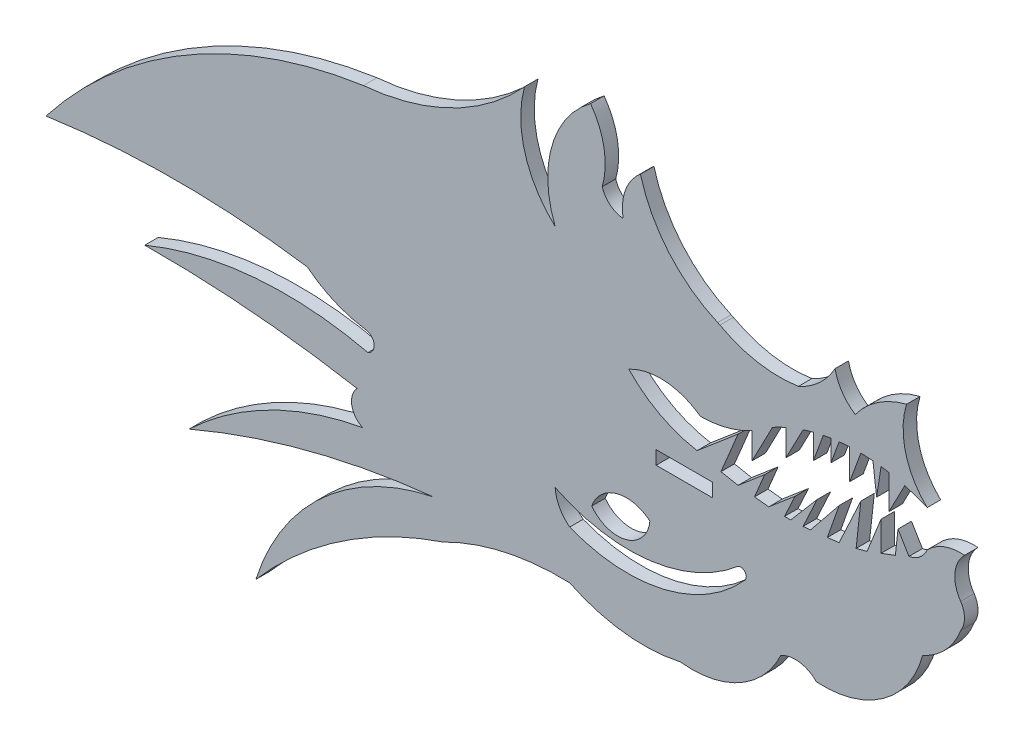
from build123d import *

# Parameters (mm, degrees)
SKETCH1_W           = 6.35
SKETCH1_H           = 1.524
BOSS_EXTRUDE1_DEPTH = 1.524


with BuildPart() as part:
    # Sketch1 → Boss-Extrude1 (new body)
    with BuildSketch(Plane.XY):
        with BuildLine():
            Line((-118.967464928, 3.837147512), (-120.210313768, 5.894153968))
            Line((-120.210313768, 5.894153968), (-120.507329985, 3.167212811))
            Line((-120.507329985, 3.167212811), (-122.125463269, 2.558958735))
            Line((-122.125463269, 2.558958735), (-122.125463269, 5.894153968))
            Line((-122.125463269, 5.894153968), (-123.701040917, 1.954785522))
            Line((-123.701040917, 1.954785522), (-124.938272303, 1.633539151))
            Line((-124.938272303, 1.633539151), (-124.405721371, 6.522952497))
            Line((-124.405721371, 6.522952497), (-126.85553137, 1.234027863))
            Line((-126.85553137, 1.234027863), (-128.185864984, 1.075304442))
            Line((-128.185864984, 1.075304442), (-126.85553137, 4.86565074))
            Line((-126.85553137, 4.86565074), (-130.098565327, 0.850073658))
            Line((-130.098565327, 0.850073658), (-130.926497191, 0.78728846))
            Line((-130.926497191, 0.78728846), (-129.340887254, 4.210481059))
            Line((-129.340887254, 4.210481059), (-132.319280434, 0.722942299))
            Line((-132.319280434, 0.722942299), (-133.020376887, 0.72112245))
            Line((-133.020376887, 0.72112245), (-131.834849185, 3.28057264))
            Line((-131.834849185, 3.28057264), (-134.796306141, 0.76870718))
            Line((-134.796306141, 0.76870718), (-136.410777473, 0.933118092))
            Line((-136.410777473, 0.933118092), (-135.265463132, 3.678674725))
            Line((-135.265463132, 3.678674725), (-138.261220774, 1.137715912))
            Line((-138.261220774, 1.137715912), (-140.197350719, 1.50653427))
            Line((-140.197350719, 1.50653427), (-138.261220774, 6.147840352))
            Line((-138.261220774, 6.147840352), (-142.88987797, 2.221879477))
            ThreePointArc((-142.88987797, 2.221879477), (-147.08283508, 3.64953129), (-150.612134583, 6.325932612))
            ThreePointArc((-150.612134583, 6.325932612), (-146.485856937, 7.203077476), (-142.522861876, 5.757317996))
            ThreePointArc((-142.522861876, 5.757317996), (-139.511076326, 6.147840352), (-136.689748679, 7.271882262))
            Line((-136.689748679, 7.271882262), (-136.689748679, 4.31406956))
            Line((-136.689748679, 4.31406956), (-134.379090787, 8.749235121))
            ThreePointArc((-134.379090787, 8.749235121), (-133.626205107, 9.140656329), (-132.857462763, 9.499937023))
            Line((-132.857462763, 9.499937023), (-132.857462763, 6.530588828))
            Line((-132.857462763, 6.530588828), (-130.926497191, 10.236958357))
            ThreePointArc((-130.926497191, 10.236958357), (-130.345173873, 10.415525196), (-129.75871249, 10.576416347))
            Line((-129.75871249, 10.576416347), (-129.75871249, 7.796759722))
            Line((-129.75871249, 7.796759722), (-128.644783844, 10.830408865))
            ThreePointArc((-128.644783844, 10.830408865), (-128.214678718, 10.910834307), (-127.782924128, 10.981874047))
            Line((-127.782924128, 10.981874047), (-127.782924128, 8.576451057))
            Line((-127.782924128, 8.576451057), (-126.85553137, 11.102092407))
            ThreePointArc((-126.85553137, 11.102092407), (-126.258208322, 11.156424297), (-125.659529634, 11.192901774))
            Line((-125.659529634, 11.192901774), (-125.659529634, 7.796759722))
            Line((-125.659529634, 7.796759722), (-124.405721372, 11.211353983))
            ThreePointArc((-124.405721372, 11.211353983), (-123.721315902, 11.188391312), (-123.038090537, 11.142117871))
            Line((-123.038090537, 11.142117871), (-122.625154661, 7.796759722))
            Line((-122.625154661, 7.796759722), (-122.125463269, 11.04361803))
            ThreePointArc((-122.125463269, 11.04361803), (-121.68108693, 10.980301708), (-121.238235987, 10.907073779))
            Line((-121.238235987, 10.907073779), (-121.238235987, 7.074194908))
            Line((-121.238235987, 7.074194908), (-119.450305834, 10.506016758))
            ThreePointArc((-119.450305834, 10.506016758), (-118.170254613, 10.11057495), (-116.919404117, 9.630701645))
            ThreePointArc((-116.919404117, 9.630701645), (-119.349830951, 13.774572734), (-119.242407582, 18.577395072))
            ThreePointArc((-119.242407582, 18.577395072), (-122.479801343, 17.135418403), (-125.032625503, 14.677145863))
            ThreePointArc((-125.032625503, 14.677145863), (-126.511437413, 16.117497101), (-127.319227749, 18.017226326))
            ThreePointArc((-127.319227749, 18.017226326), (-129.072821157, 15.778913608), (-131.451278595, 14.220685806))
            ThreePointArc((-131.451278595, 14.220685806), (-136.013842114, 14.266990808), (-140.318864701, 15.778913608))
            Line((-140.318864701, 15.778913608), (-140.572063038, 15.900311384))
            ThreePointArc((-140.572063038, 15.900311384), (-146.082089593, 19.986277928), (-149.28772088, 26.05088371))
            ThreePointArc((-149.28772088, 26.05088371), (-150.98225883, 23.655808523), (-151.240302387, 20.733265531))
            ThreePointArc((-151.240302387, 20.733265531), (-152.718101686, 21.336819353), (-153.601407922, 22.66645768))
            ThreePointArc((-153.601407922, 22.66645768), (-153.396919216, 26.552679329), (-154.91417797, 30.136317175))
            ThreePointArc((-154.91417797, 30.136317175), (-159.291131596, 23.805118938), (-158.91395171, 16.117497101))
            ThreePointArc((-158.91395171, 16.117497101), (-162.327187611, 21.593822413), (-162.381546066, 28.046524436))
            ThreePointArc((-162.381546066, 28.046524436), (-170.625215942, 21.84762456), (-180.560631507, 19.077792393))
            ThreePointArc((-180.560631507, 19.077792393), (-200.503081439, 12.098235462), (-216.39853294, -1.821180682))
            ThreePointArc((-216.39853294, -1.821180682), (-201.656488756, -0.752866976), (-186.914444571, -1.821180682))
            ThreePointArc((-186.914444571, -1.821180682), (-183.850945452, -3.661612396), (-180.414923023, -4.644447892))
            ThreePointArc((-180.414923023, -4.644447892), (-179.359692742, -5.560033265), (-180.052236488, -6.773371915))
            ThreePointArc((-180.052236488, -6.773371915), (-192.817706831, -5.844622664), (-205.252520527, -8.876984225))
            ThreePointArc((-205.252520527, -8.876984225), (-193.210647633, -9.328958481), (-181.263188413, -10.900327847))
            ThreePointArc((-181.263188413, -10.900327847), (-181.878443359, -12.812123131), (-180.664874061, -14.412357306))
            ThreePointArc((-180.664874061, -14.412357306), (-191.17895358, -17.957183031), (-200.243848586, -24.35556846))
            ThreePointArc((-200.243848586, -24.35556846), (-186.726305796, -19.732822879), (-172.667325525, -17.19534115))
            ThreePointArc((-172.667325525, -17.19534115), (-185.150029357, -23.504388145), (-192.700842194, -35.277543815))
            ThreePointArc((-192.700842194, -35.277543815), (-183.0911903, -26.748605396), (-171.570271252, -21.060317047))
            ThreePointArc((-171.570271252, -21.060317047), (-164.623433194, -18.575118247), (-157.275939172, -17.904966269))
            ThreePointArc((-157.275939172, -17.904966269), (-151.145420538, -19.702741956), (-144.764510502, -19.387712987))
            ThreePointArc((-144.764510502, -19.387712987), (-138.075773009, -18.065674232), (-133.430936261, -13.074433174))
            ThreePointArc((-133.430936261, -13.074433174), (-131.329864526, -12.686756633), (-129.424108432, -13.652618554))
            ThreePointArc((-129.424108432, -13.652618554), (-121.886353154, -11.514694937), (-117.426632435, -5.072695004))
            ThreePointArc((-117.426632435, -5.072695004), (-114.82444132, -3.21357396), (-113.136821812, -0.497019148))
            ThreePointArc((-113.136821812, -0.497019148), (-112.701188688, 0.934666439), (-113.136821812, 2.366352026))
            ThreePointArc((-113.136821812, 2.366352026), (-113.78472542, 4.800381574), (-112.701188688, 7.074194908))
            ThreePointArc((-112.701188688, 7.074194908), (-114.988500666, 6.766664074), (-116.919404117, 5.502550489))
            ThreePointArc((-116.919404117, 5.502550489), (-117.728663328, 4.405730062), (-118.967464928, 3.837147512))
        make_face()
        with Locations((-144.335438151, -0.762)):
            Rectangle(SKETCH1_W, SKETCH1_H, mode=Mode.SUBTRACT)
        with BuildLine():
            ThreePointArc((-137.559244953, -7.819206053), (-146.689526794, -13.235024078), (-157.275939172, -12.446985783))
            ThreePointArc((-157.275939172, -12.446985783), (-158.429212855, -11.102896957), (-158.91395171, -9.399475928))
            ThreePointArc((-158.91395171, -9.399475928), (-148.192505964, -11.193493039), (-138.261220774, -6.773371915))
            ThreePointArc((-138.261220774, -6.773371915), (-137.447536507, -6.985721903), (-137.559244953, -7.819206053))
        make_face(mode=Mode.SUBTRACT)
        with BuildLine():
            ThreePointArc((-148.216931549, -7.339340233), (-151.974990586, -6.526199766), (-154.789067747, -9.14634764))
            ThreePointArc((-154.789067747, -9.14634764), (-150.886892893, -10.483641343), (-148.216931549, -7.339340233))
        make_face(mode=Mode.SUBTRACT)
    extrude(amount=BOSS_EXTRUDE1_DEPTH)


solid = part.part
